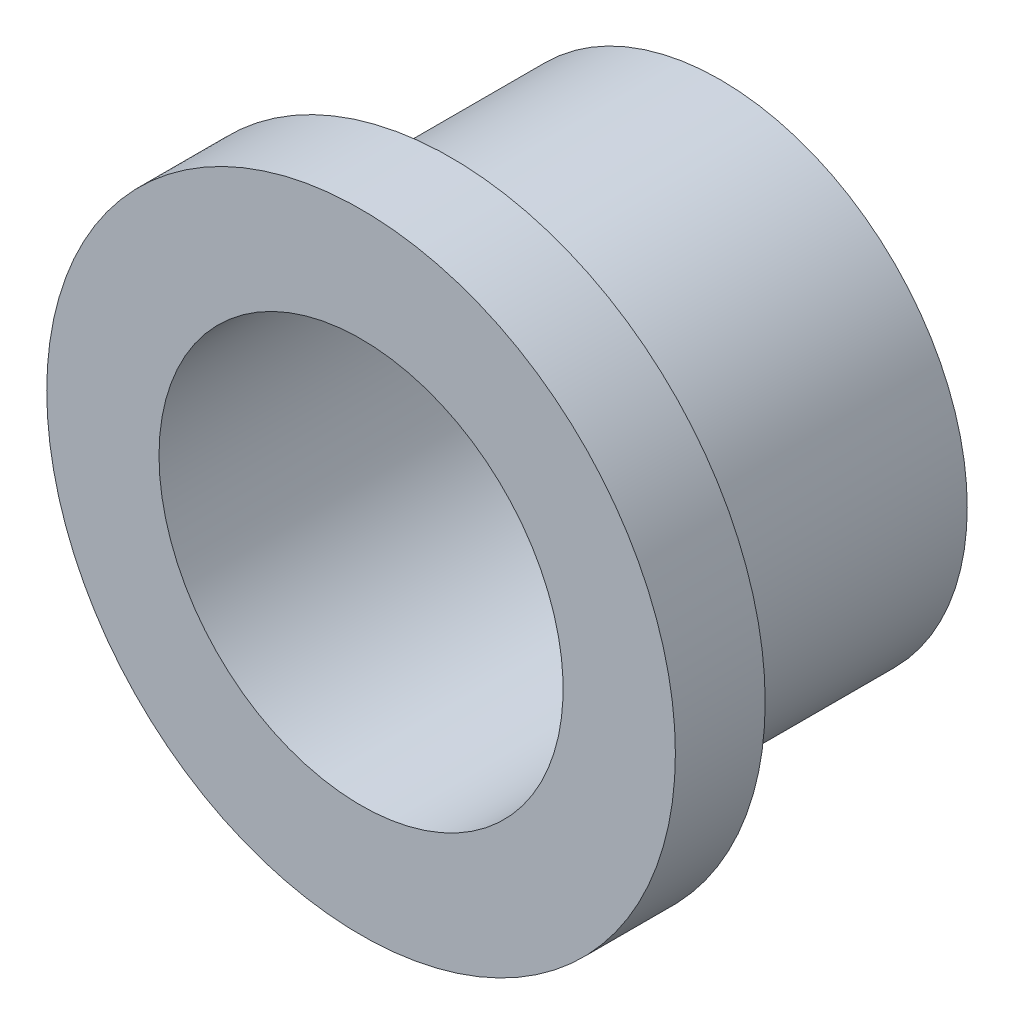
from build123d import *

# Parameters (mm, degrees)
SKETCH2_R               = 27.5
SKETCH2_R_2             = 22.5
BOSS_EXTRUDE2_DEPTH     = 15
SKETCH3_R               = 35
BOSS_EXTRUDE3_DEPTH     = 10
SKETCH4_R               = 22.5
CUT_EXTRUDE1_DEPTH      = 31
CUT_EXTRUDE1_DEPTH_BACK = 11


with BuildPart() as part:
    # Sketch2 → Boss-Extrude2 (new body, symmetric)
    with BuildSketch(Plane.XY):
        Circle(SKETCH2_R)
        Circle(SKETCH2_R_2, mode=Mode.SUBTRACT)
    extrude(amount=BOSS_EXTRUDE2_DEPTH, both=True)

    # Sketch3 → Boss-Extrude3 (add)
    with BuildSketch(Plane.XY.offset(15)):
        Circle(SKETCH3_R)
    extrude(amount=BOSS_EXTRUDE3_DEPTH)

    # Sketch4 → Cut-Extrude1 (cut, two sides)
    with BuildSketch(Plane(origin=(0, 0, 15), x_dir=(-1, 0, 0), z_dir=(0, 0, -1))) as cut_extrude1_sk:
        Circle(SKETCH4_R)
    extrude(amount=CUT_EXTRUDE1_DEPTH, mode=Mode.SUBTRACT)
    extrude(cut_extrude1_sk.sketch, amount=-CUT_EXTRUDE1_DEPTH_BACK, mode=Mode.SUBTRACT)


solid = part.part
